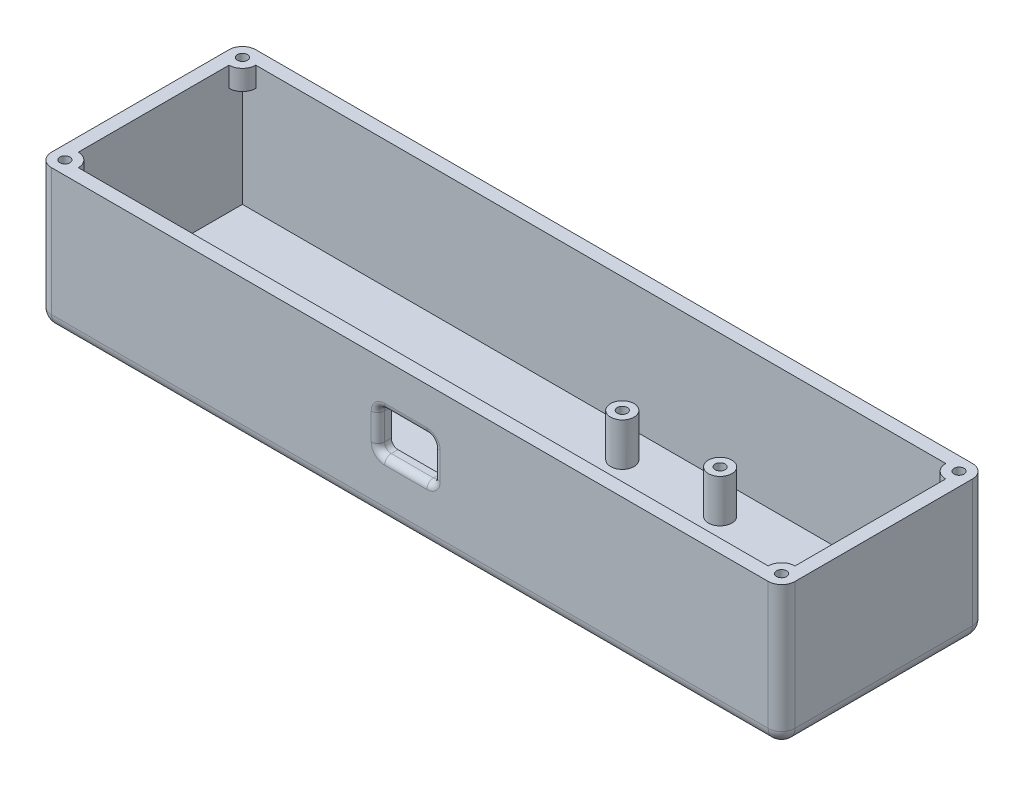
from build123d import *

# Parameters (mm, degrees)
SKETCH1_W           = 111
SKETCH1_H           = 30.5
BOSS_EXTRUDE1_DEPTH = 2
SKETCH2_W           = 111
SKETCH2_H           = 30.5
SKETCH2_W_2         = 107
SKETCH2_H_2         = 26.5
BOSS_EXTRUDE2_DEPTH = 19
FILLET1_R           = 2
SKETCH4_R           = 2
BOSS_EXTRUDE4_DEPTH = 3
SKETCH5_R           = 1.75
SKETCH5_R_2         = 0.75
BOSS_EXTRUDE5_DEPTH = 6.4
SKETCH6_W           = 8.3
SKETCH6_H           = 6
CUT_EXTRUDE1_DEPTH  = 2
FILLET2_R           = 1
SKETCH7_R           = 0.75
CUT_EXTRUDE3_DEPTH  = 2.5
FILLET3_R           = 1


with BuildPart() as part:
    # Sketch1 → Boss-Extrude1 (new body)
    with BuildSketch(Plane(origin=(0, 0, 0), x_dir=(1, 0, 0), z_dir=(0, 1, 0))):
        with Locations((55.5, 15.25)):
            Rectangle(SKETCH1_W, SKETCH1_H)
    extrude(amount=BOSS_EXTRUDE1_DEPTH)

    # Sketch2 → Boss-Extrude2 (add)
    with BuildSketch(Plane(origin=(0, 2, 0), x_dir=(1, 0, 0), z_dir=(0, 1, 0))):
        with Locations((55.5, 15.25)):
            Rectangle(SKETCH2_W, SKETCH2_H)
        with Locations((55.5, 15.25)):
            Rectangle(SKETCH2_W_2, SKETCH2_H_2, mode=Mode.SUBTRACT)
    extrude(amount=BOSS_EXTRUDE2_DEPTH)

    # Fillet1
    fillet1_edges = [part.edges().sort_by_distance(p)[0] for p in [
        (55.5, 0, -30.5),
        (111, 0, -15.25),
        (55.5, 0, 0),
        (0, 0, -15.25),
        (0, 10.5, -30.5),
        (111, 10.5, -30.5),
        (111, 10.5, 0),
        (0, 10.5, 0),
    ]]
    fillet(fillet1_edges, radius=FILLET1_R)

    # Sketch4 → Boss-Extrude4 (add)
    with BuildSketch(Plane(origin=(0, 21, 0), x_dir=(1, 0, 0), z_dir=(0, 1, 0))):
        with Locations((2, 28.5)):
            Circle(SKETCH4_R)
        with Locations((2, 2)):
            Circle(SKETCH4_R)
        with Locations((109, 2)):
            Circle(SKETCH4_R)
        with Locations((109, 28.5)):
            Circle(SKETCH4_R)
    extrude(amount=-BOSS_EXTRUDE4_DEPTH)

    # Sketch5 → Boss-Extrude5 (add)
    with BuildSketch(Plane(origin=(0, 2, 0), x_dir=(1, 0, 0), z_dir=(0, 1, 0))):
        with Locations((63.39, 23.825)):
            Circle(SKETCH5_R)
        with Locations((63.39, 23.825)):
            Circle(SKETCH5_R_2, mode=Mode.SUBTRACT)
        with Locations((63.39, 6.675)):
            Circle(SKETCH5_R)
        with Locations((63.39, 6.675)):
            Circle(SKETCH5_R_2, mode=Mode.SUBTRACT)
        with Locations((78, 6.675)):
            Circle(SKETCH5_R)
        with Locations((78, 6.675)):
            Circle(SKETCH5_R_2, mode=Mode.SUBTRACT)
        with Locations((78, 23.825)):
            Circle(SKETCH5_R)
        with Locations((78, 23.825)):
            Circle(SKETCH5_R_2, mode=Mode.SUBTRACT)
    extrude(amount=BOSS_EXTRUDE5_DEPTH)

    # Sketch6 → Cut-Extrude1 (cut)
    with BuildSketch(Plane.XY):
        with Locations((54.88, 11.4)):
            Rectangle(SKETCH6_W, SKETCH6_H)
    extrude(amount=-CUT_EXTRUDE1_DEPTH, mode=Mode.SUBTRACT)

    # Fillet2
    fillet2_edges = [part.edges().sort_by_distance(p)[0] for p in [
        (59.03, 8.4, -1),
        (59.03, 14.4, -1),
        (50.73, 14.4, -1),
        (50.73, 8.4, -1),
    ]]
    fillet(fillet2_edges, radius=FILLET2_R)

    # Sketch7 → Cut-Extrude3 (cut)
    with BuildSketch(Plane(origin=(0, 21, 0), x_dir=(1, 0, 0), z_dir=(0, 1, 0))):
        with Locations((2, 28.5)):
            Circle(SKETCH7_R)
        with Locations((2, 2)):
            Circle(SKETCH7_R)
        with Locations((109, 2)):
            Circle(SKETCH7_R)
        with Locations((109, 28.5)):
            Circle(SKETCH7_R)
    extrude(amount=-CUT_EXTRUDE3_DEPTH, mode=Mode.SUBTRACT)

    # Fillet3
    fillet3_edges = [part.edges().sort_by_distance(p)[0] for p in [
        (54.88, 14.4, 0),
        (59.03, 11.4, 0),
        (50.73, 11.4, 0),
        (54.88, 8.4, 0),
        (58.737106781, 14.107106781, 0),
        (51.022893219, 14.107106781, 0),
        (51.022893219, 8.692893219, 0),
        (58.737106781, 8.692893219, 0),
    ]]
    fillet(fillet3_edges, radius=FILLET3_R)


solid = part.part
